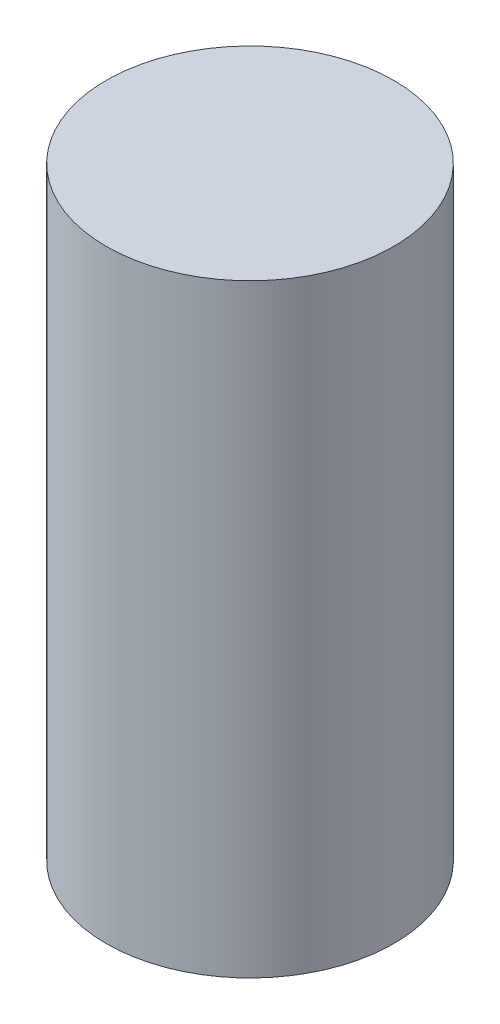
from build123d import *

# Parameters (mm, degrees)
SKETCH1_R           = 2.38125
BOSS_EXTRUDE1_DEPTH = 10


with BuildPart() as part:
    # Sketch1 → Boss-Extrude1 (new body)
    with BuildSketch(Plane(origin=(0, 0, 0), x_dir=(1, 0, 0), z_dir=(0, 1, 0))):
        Circle(SKETCH1_R)
    extrude(amount=BOSS_EXTRUDE1_DEPTH)


solid = part.part
